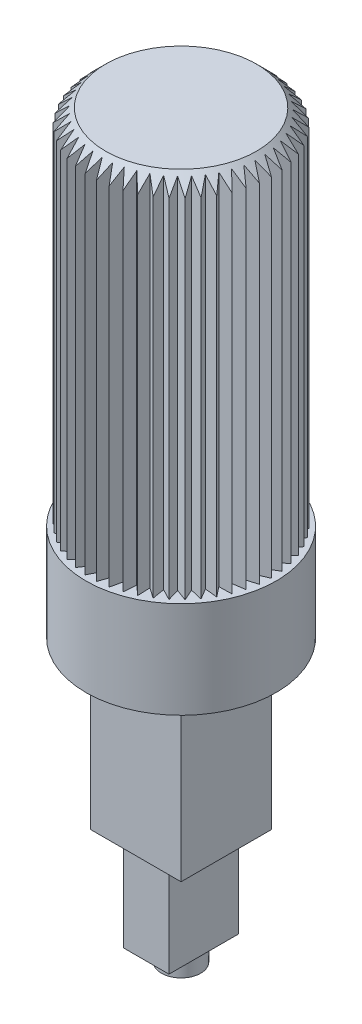
from build123d import *

# Parameters (mm, degrees)
SKETCH_1_R               = 3.15
EXTRUDE_1_DEPTH          = 3.2
SKETCH_2_R               = 3
EXTRUDE_2_DEPTH          = 12
CHAMFER_1_SIZE           = 0.5
SKETCH_3_W               = 3
SKETCH_3_H               = 3
EXTRUDE_3_DEPTH          = 5.5
SKETCH_4_W               = 1.5
SKETCH_4_H               = 2.3
EXTRUDE_4_DEPTH          = 3.2
SKETCH_5_R               = 0.65
EXTRUDE_5_DEPTH          = 0.6
CUT_EXTRUDE_1_DEPTH      = 12
PATTERN_CIRCULAR_1_COUNT = 50


with BuildPart() as part:
    # Эскиз1 → Бобышка-Вытянуть1 (new body)
    with BuildSketch(Plane(origin=(0, 0, 0), x_dir=(1, 0, 0), z_dir=(0, 1, 0))):
        Circle(SKETCH_1_R)
    extrude(amount=EXTRUDE_1_DEPTH)

    # Эскиз2 → Бобышка-Вытянуть2 (add)
    with BuildSketch(Plane(origin=(0, 3.2, 0), x_dir=(1, 0, 0), z_dir=(0, 1, 0))):
        Circle(SKETCH_2_R)
    extrude(amount=EXTRUDE_2_DEPTH)

    # Фаска1
    chamfer_1_edges = [part.edges().sort_by_distance(p)[0] for p in [
        (-3, 15.2, 0),
    ]]
    chamfer(chamfer_1_edges, length=CHAMFER_1_SIZE)

    # Эскиз3 → Бобышка-Вытянуть3 (add)
    with BuildSketch(Plane.XZ):
        Rectangle(SKETCH_3_W, SKETCH_3_H)
    extrude(amount=EXTRUDE_3_DEPTH)

    # Эскиз4 → Бобышка-Вытянуть4 (add)
    with BuildSketch(Plane.XZ.offset(5.5)):
        Rectangle(SKETCH_4_W, SKETCH_4_H)
    extrude(amount=EXTRUDE_4_DEPTH)

    # Эскиз5 → Бобышка-Вытянуть5 (add)
    with BuildSketch(Plane.XZ.offset(8.7)):
        Circle(SKETCH_5_R)
    extrude(amount=EXTRUDE_5_DEPTH)

    # Эскиз7 → Вырез-Вытянуть1 (cut)
    with BuildSketch(Plane(origin=(0, 15.2, 0), x_dir=(1, 0, 0), z_dir=(0, 1, 0))):
        Polygon((0, 2.612170904), (-0.2, 3.012170904), (0.2, 3.012170904), align=None)
    cut_extrude_1 = extrude(amount=-CUT_EXTRUDE_1_DEPTH, mode=Mode.SUBTRACT)

    # Круговой массив1: Вырез-Вытянуть1 ×50 about axis
    pattern_circular_1_axis = Axis((0, 0, 0), (0, 1, 0))
    for i in range(1, PATTERN_CIRCULAR_1_COUNT):
        add(cut_extrude_1.rotate(pattern_circular_1_axis, i * 360 / PATTERN_CIRCULAR_1_COUNT), mode=Mode.SUBTRACT)


solid = part.part
